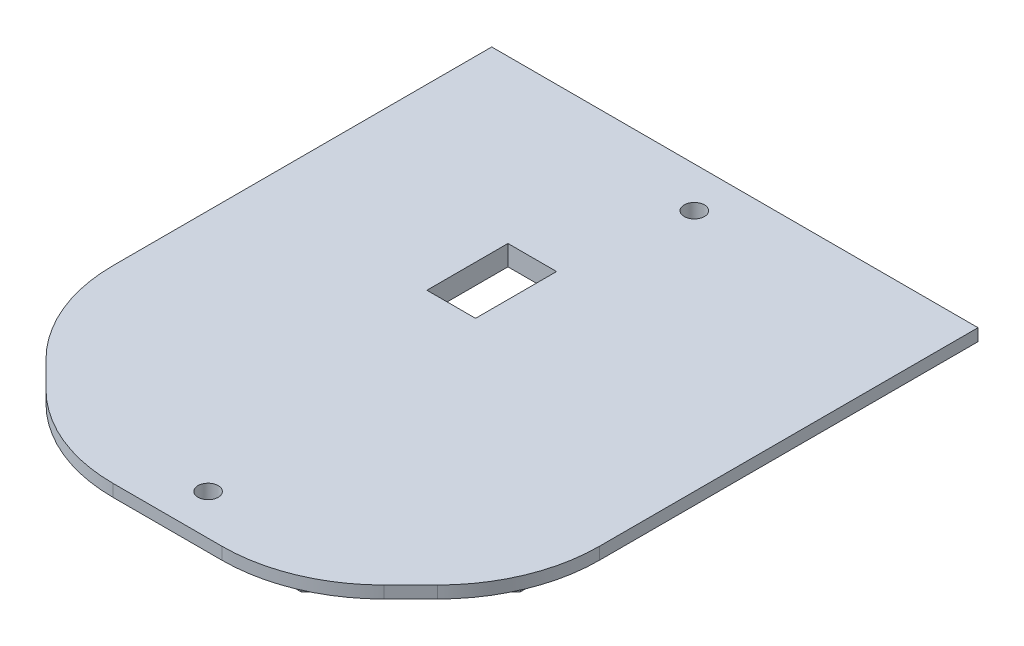
from build123d import *

# Parameters (mm, degrees)
SKETCH1_R           = 3.175
BOSS_EXTRUDE1_DEPTH = 3.81
SKETCH2_R           = 3.175
BOSS_EXTRUDE2_DEPTH = 2.54
FILLET1_R           = 50.8
SKETCH3_W           = 15.24
SKETCH3_H           = 25.4
CUT_EXTRUDE1_DEPTH  = 7.35


with BuildPart() as part:
    # Sketch1 → Boss-Extrude1 (new body)
    with BuildSketch(Plane(origin=(0, 0, 0), x_dir=(1, 0, 0), z_dir=(0, 1, 0))):
        Polygon((-76.2, -50.8), (-38.1, -88.9), (38.1, -88.9), (76.2, -50.8), (76.2, 88.9), (-76.2, 88.9), align=None)
        with Locations((0, 76.2)):
            Circle(SKETCH1_R, mode=Mode.SUBTRACT)
        with Locations((0, -76.2)):
            Circle(SKETCH1_R, mode=Mode.SUBTRACT)
    extrude(amount=BOSS_EXTRUDE1_DEPTH)

    # Sketch2 → Boss-Extrude2 (add)
    with BuildSketch(Plane.XZ):
        Polygon((-69.85, 48.169743879), (-69.85, -82.55), (69.85, -82.55), (69.85, 48.169743879), (35.469743879, 82.55), (-35.469743879, 82.55), align=None)
        with Locations((0, 76.2)):
            Circle(SKETCH2_R, mode=Mode.SUBTRACT)
        with Locations((0, -76.2)):
            Circle(SKETCH2_R, mode=Mode.SUBTRACT)
    extrude(amount=BOSS_EXTRUDE2_DEPTH)

    # Fillet1
    fillet1_edges = [part.edges().sort_by_distance(p)[0] for p in [
        (76.2, 1.905, 50.8),
        (38.1, 1.905, 88.9),
        (-38.1, 1.905, 88.9),
        (-76.2, 1.905, 50.8),
    ]]
    fillet(fillet1_edges, radius=FILLET1_R)

    # Sketch3 → Cut-Extrude1 (cut, through all)
    with BuildSketch(Plane(origin=(0, 3.81, 0), x_dir=(1, 0, 0), z_dir=(0, 1, 0))):
        with Locations((-12.7, 25.4)):
            Rectangle(SKETCH3_W, SKETCH3_H)
    extrude(amount=-CUT_EXTRUDE1_DEPTH, mode=Mode.SUBTRACT)


solid = part.part
